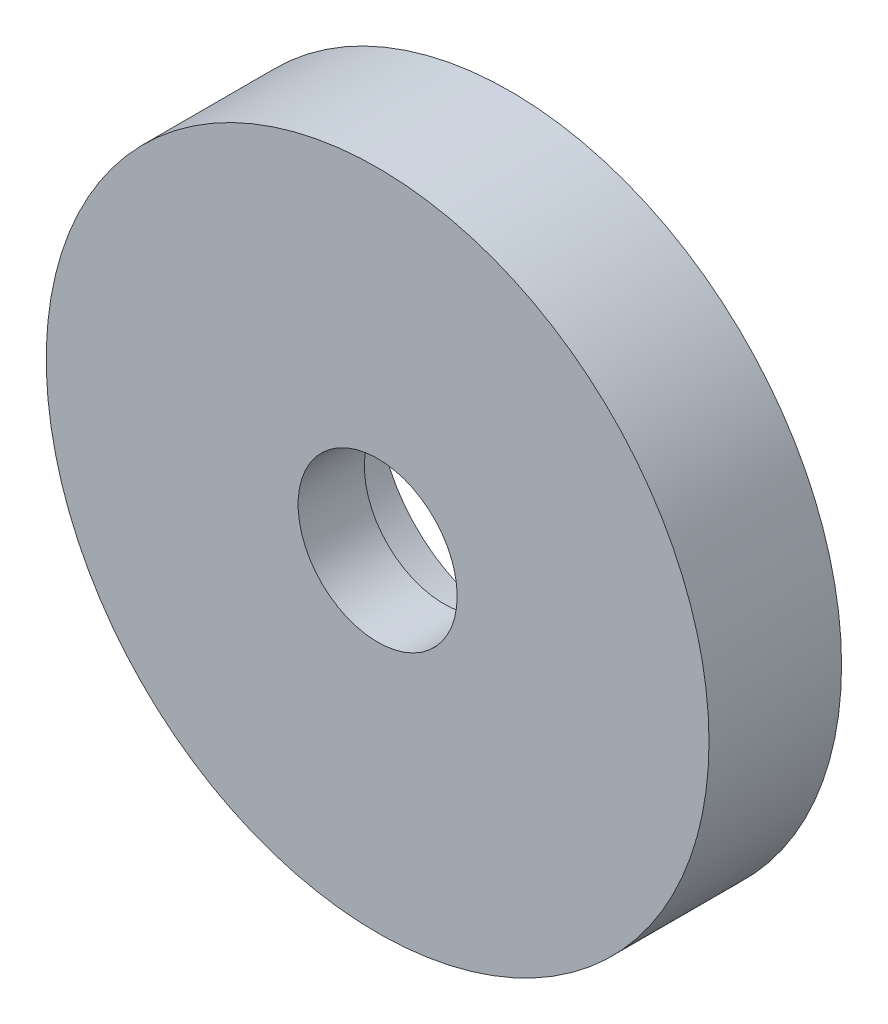
from build123d import *

# Parameters (mm, degrees)
SKETCH2_R           = 25
BOSS_EXTRUDE1_DEPTH = 10
SKETCH3_R           = 6
CUT_EXTRUDE1_DEPTH  = 5
SKETCH4_R           = 10
CUT_EXTRUDE2_DEPTH  = 5


with BuildPart() as part:
    # Sketch2 → Boss-Extrude1 (new body)
    with BuildSketch(Plane.XY):
        Circle(SKETCH2_R)
    extrude(amount=BOSS_EXTRUDE1_DEPTH)

    # Sketch3 → Cut-Extrude1 (cut)
    with BuildSketch(Plane.XY.offset(10)):
        Circle(SKETCH3_R)
    extrude(amount=-CUT_EXTRUDE1_DEPTH, mode=Mode.SUBTRACT)

    # Sketch4 → Cut-Extrude2 (cut)
    with BuildSketch(Plane(origin=(0, 0, 0), x_dir=(-1, 0, 0), z_dir=(0, 0, -1))):
        Circle(SKETCH4_R)
    extrude(amount=-CUT_EXTRUDE2_DEPTH, mode=Mode.SUBTRACT)


solid = part.part
